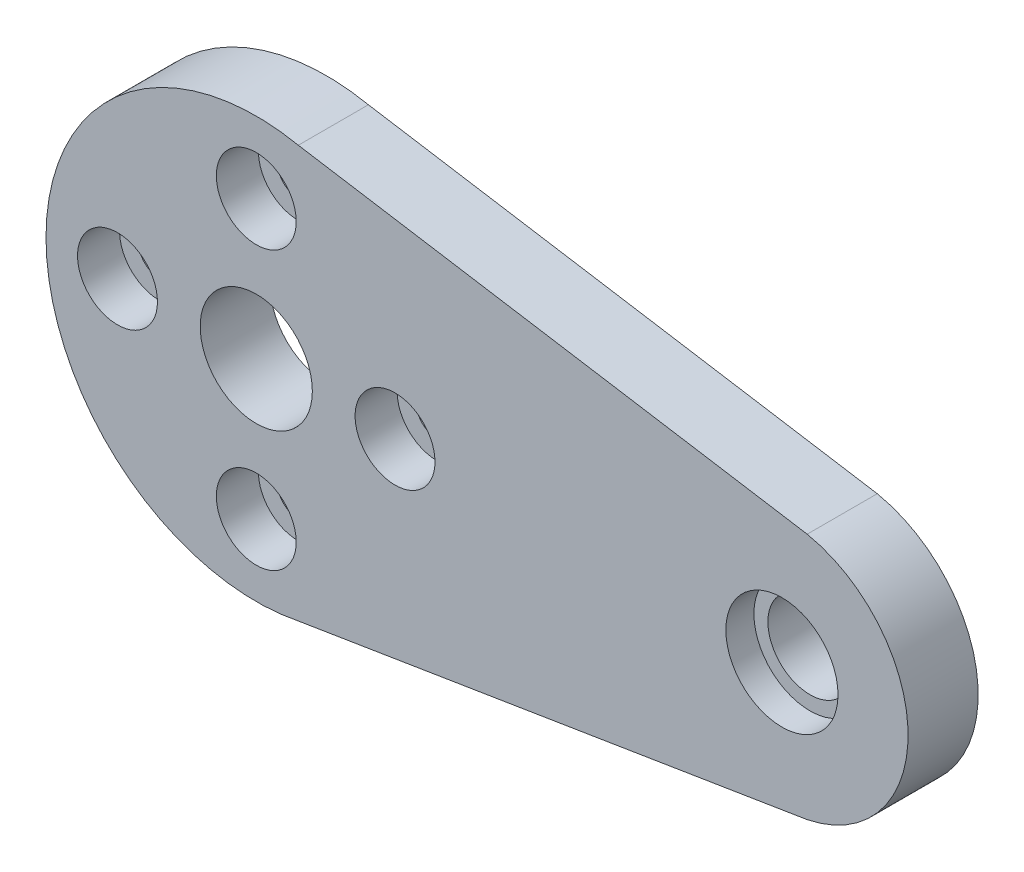
from build123d import *

# Parameters (mm, degrees)
SKETCH_1_R          = 4
EXTRUDE_1_DEPTH     = 5
SKETCH_2_R          = 4
SKETCH_2_R_2        = 3
EXTRUDE_2_DEPTH     = 3
SKETCH_3_R          = 1.5
CUT_EXTRUDE_1_DEPTH = 10
SKETCH_4_R          = 2.85
CUT_EXTRUDE_2_DEPTH = 3


with BuildPart() as part:
    # 草图1 → 凸台-拉伸1 (new body)
    with BuildSketch(Plane.XY):
        with BuildLine():
            Line((23.05, 8.65181281), (-13.25, 14.530588193))
            ThreePointArc((-13.25, 14.530588193), (-31.25, -0.166350264), (-13.25, -14.86328872))
            Line((-13.25, -14.86328872), (23.05, -8.984513338))
            ThreePointArc((23.05, -8.984513338), (30.25, -0.166350264), (23.05, 8.65181281))
        make_face()
        with Locations((21.25, -0.166350264)):
            Circle(SKETCH_1_R, mode=Mode.SUBTRACT)
        with Locations((-16.25, -0.166350264)):
            Circle(SKETCH_1_R, mode=Mode.SUBTRACT)
    extrude(amount=EXTRUDE_1_DEPTH)

    # 草图2 → 凸台-拉伸2 (add)
    with BuildSketch(Plane(origin=(0, 0, 0), x_dir=(-1, 0, 0), z_dir=(0, 0, -1))):
        with Locations((-21.25, -0.166350264)):
            Circle(SKETCH_2_R)
        with Locations((-21.25, -0.166350264)):
            Circle(SKETCH_2_R_2, mode=Mode.SUBTRACT)
    extrude(amount=-EXTRUDE_2_DEPTH)

    # 草图3 → 切除-拉伸1 (cut)
    with BuildSketch(Plane.XY.offset(5)):
        with Locations((-16.25, 9.733649736)):
            Circle(SKETCH_3_R)
        with Locations((-6.35, -0.166350264)):
            Circle(SKETCH_3_R)
        with Locations((-26.15, -0.166350264)):
            Circle(SKETCH_3_R)
        with Locations((-16.25, -10.066350264)):
            Circle(SKETCH_3_R)
    extrude(amount=-CUT_EXTRUDE_1_DEPTH, mode=Mode.SUBTRACT)

    # 草图4 → 切除-拉伸2 (cut)
    with BuildSketch(Plane.XY.offset(5)):
        with Locations((-16.25, 9.733649736)):
            Circle(SKETCH_4_R)
        with Locations((-26.15, -0.166350264)):
            Circle(SKETCH_4_R)
        with Locations((-6.35, -0.166350264)):
            Circle(SKETCH_4_R)
        with Locations((-16.25, -10.066350264)):
            Circle(SKETCH_4_R)
    extrude(amount=-CUT_EXTRUDE_2_DEPTH, mode=Mode.SUBTRACT)


solid = part.part
